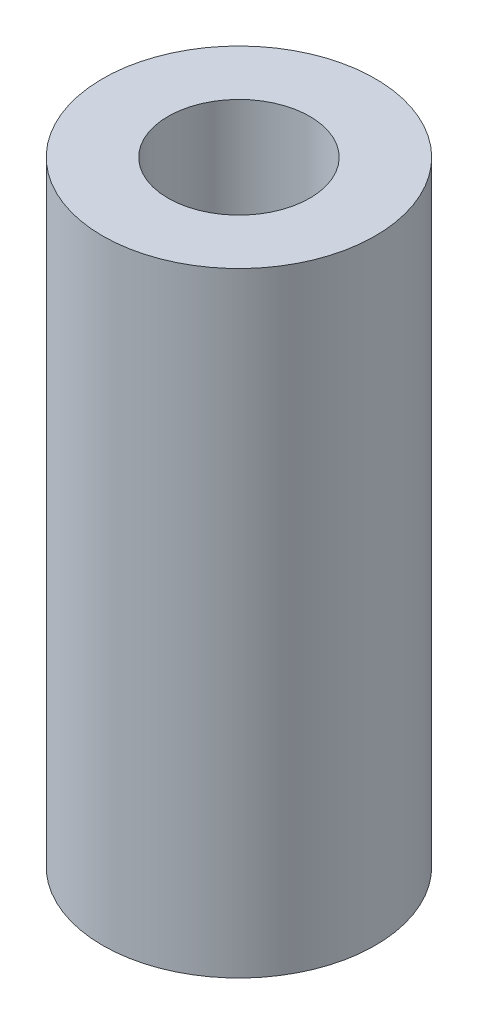
from build123d import *

# Parameters (mm, degrees)
SKETCH2_R           = 3.662175342
SKETCH2_R_2         = 1.905
BOSS_EXTRUDE1_DEPTH = 16.51


with BuildPart() as part:
    # Sketch2 → Boss-Extrude1 (new body)
    with BuildSketch(Plane(origin=(0, 0, 0), x_dir=(1, 0, 0), z_dir=(0, 1, 0))):
        Circle(SKETCH2_R)
        Circle(SKETCH2_R_2, mode=Mode.SUBTRACT)
    extrude(amount=BOSS_EXTRUDE1_DEPTH)


solid = part.part
